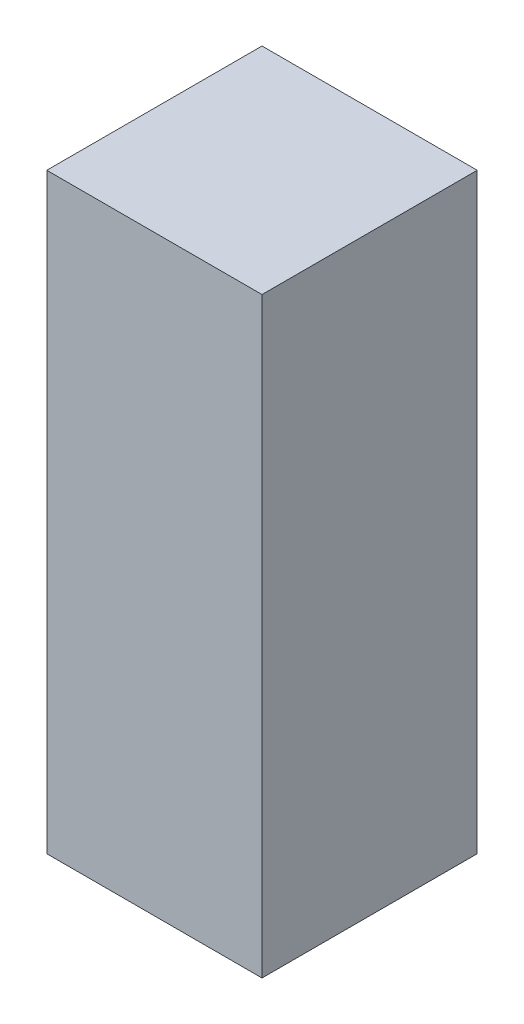
from build123d import *

# Parameters (mm, degrees)
SKETCH1_W           = 40
SKETCH1_H           = 40
BOSS_EXTRUDE1_DEPTH = 110


with BuildPart() as part:
    # Sketch1 → Boss-Extrude1 (new body)
    with BuildSketch(Plane(origin=(0, 0, 0), x_dir=(1, 0, 0), z_dir=(0, 1, 0))):
        Rectangle(SKETCH1_W, SKETCH1_H)
    extrude(amount=BOSS_EXTRUDE1_DEPTH)


solid = part.part
